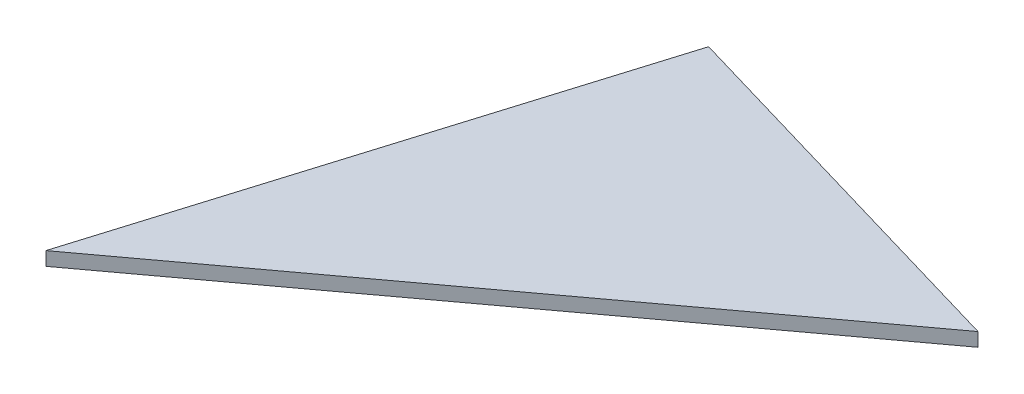
from build123d import *

# Parameters (mm, degrees)
BOSS_EXTRU_1_DEPTH = 2


with BuildPart() as part:
    # Esquisse1 → Boss.-Extru.1 (new body)
    with BuildSketch(Plane(origin=(0, 0, 0), x_dir=(1, 0, 0), z_dir=(0, 1, 0))):
        Polygon((22.671953786, 74.408864904), (0, 0), (78.542738023, 58.002249204), align=None)
    extrude(amount=BOSS_EXTRU_1_DEPTH)


solid = part.part
